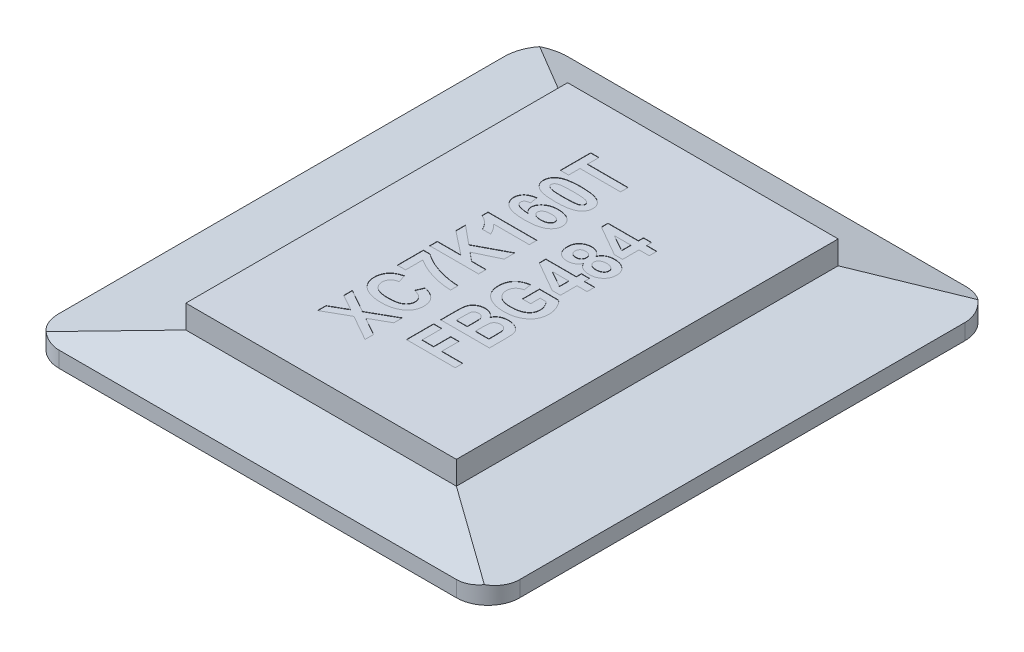
from build123d import *

# Parameters (mm, degrees)
SKETCH1_W           = 14.54
SKETCH1_H           = 16.05
SKETCH2_W           = 8.54
SKETCH2_H           = 12.05
SKETCH3_W           = 8.54
SKETCH3_H           = 12.05
BOSS_EXTRUDE1_DEPTH = 0.735
SKETCH4_W           = 14.54
SKETCH4_H           = 16.05
BOSS_EXTRUDE2_DEPTH = 0.5
FILLET1_R           = 1
CUT_EXTRUDE1_DEPTH  = 0.01


with BuildPart() as part:
    # Sketch1 → Loft1 section 0
    with BuildSketch(Plane(origin=(0, 0, 0), x_dir=(1, 0, 0), z_dir=(0, 1, 0))):
        Rectangle(SKETCH1_W, SKETCH1_H)
    # Sketch2 → Loft1 section 1
    with BuildSketch(Plane(origin=(0, 0.55, 0), x_dir=(1, 0, 0), z_dir=(0, 1, 0))):
        Rectangle(SKETCH2_W, SKETCH2_H)
    loft()

    # Sketch3 → Boss-Extrude1 (add)
    with BuildSketch(Plane(origin=(0, 0.55, 0), x_dir=(1, 0, 0), z_dir=(0, 1, 0))):
        Rectangle(SKETCH3_W, SKETCH3_H)
    extrude(amount=BOSS_EXTRUDE1_DEPTH)

    # Sketch4 → Boss-Extrude2 (add)
    with BuildSketch(Plane.XZ):
        Rectangle(SKETCH4_W, SKETCH4_H)
    extrude(amount=BOSS_EXTRUDE2_DEPTH)

    # Fillet1
    fillet1_edges = [part.edges().sort_by_distance(p)[0] for p in [
        (7.27, -0.25, -8.025),
        (7.27, -0.25, 8.025),
        (-7.27, -0.25, 8.025),
        (-7.27, -0.25, -8.025),
    ]]
    fillet(fillet1_edges, radius=FILLET1_R)

    # Sketch5 → Cut-Extrude1 (cut)
    with BuildSketch(Plane(origin=(0, 1.285, 0), x_dir=(1, 0, 0), z_dir=(0, 1, 0))):
        Polygon((-0.448599451, -4.189884652), (-1.254430285, -3.734904496), (-1.989590662, -4.149858907), (-1.989590662, -3.879372422), (-1.494272059, -3.599504903), (-1.989590662, -3.319950085), (-1.989590662, -3.049150899), (-1.254430285, -3.46410531), (-0.448599451, -3.009125153), (-0.448599451, -3.279924339), (-1.014901213, -3.599504903), (-0.448599451, -3.919398168), align=None)
        with BuildLine():
            Line((-1.008959891, -2.068520128), (-0.908895527, -1.828365654))
            add(Edge.make_bspline(
                [(-0.908895527, -1.828365654), (-0.888708576, -1.833325952), (-0.849373305, -1.842991337), (-0.79314809, -1.861269526), (-0.740994552, -1.881409321), (-0.693218524, -1.904317964), (-0.649545746, -1.929635351), (-0.610060714, -1.957438325), (-0.57469807, -1.987621032), (-0.543577524, -2.020222239), (-0.516763793, -2.05518463), (-0.492987786, -2.091657934), (-0.472973466, -2.130188219), (-0.456549887, -2.170792406), (-0.444239034, -2.213388319), (-0.435006742, -2.257792235), (-0.4297163, -2.304168461), (-0.428967389, -2.335762336), (-0.428586578, -2.35182736)],
                knots=[0, 0, 0, 0, 6.2344e-05, 0.00012148, 0.000177226, 0.000229954, 0.000280261, 0.000328499, 0.000374626, 0.000419526, 0.000463434, 0.000506629, 0.000549986, 0.000593479, 0.000637807, 0.000682821, 0.000729405, 0.000777598, 0.000777598, 0.000777598, 0.000777598], degree=3))
            add(Edge.make_bspline(
                [(-0.428586578, -2.35182736), (-0.429039748, -2.371983967), (-0.429927498, -2.411470283), (-0.439479462, -2.469088407), (-0.453992007, -2.523917016), (-0.474832114, -2.575857277), (-0.501470207, -2.62497078), (-0.534465398, -2.670738686), (-0.572589332, -2.714228946), (-0.602314765, -2.739515537), (-0.617458066, -2.752397518)],
                knots=[0, 0, 0, 0, 6.0417e-05, 0.000118355, 0.000174715, 0.000230286, 0.000285838, 0.000341891, 0.000399255, 0.000458827, 0.000458827, 0.000458827, 0.000458827], degree=3))
            add(Edge.make_bspline(
                [(-0.617458066, -2.752397518), (-0.636154372, -2.766557404), (-0.673819809, -2.795083803), (-0.735930048, -2.830897112), (-0.802657061, -2.86135702), (-0.874061328, -2.886286952), (-0.950221955, -2.90571852), (-1.031175252, -2.919303708), (-1.116882063, -2.927462029), (-1.175611361, -2.928528306), (-1.205648908, -2.929073662)],
                knots=[0, 0, 0, 0, 7.0304e-05, 0.000141634, 0.000214537, 0.000290094, 0.000368212, 0.000450053, 0.000536118, 0.00062622, 0.00062622, 0.00062622, 0.00062622], degree=3))
            add(Edge.make_bspline(
                [(-1.205648908, -2.929073662), (-1.237357784, -2.92857544), (-1.299121356, -2.927604987), (-1.389043244, -2.918867531), (-1.473818183, -2.905547655), (-1.553131079, -2.885688271), (-1.627437351, -2.860810019), (-1.696273637, -2.830073009), (-1.760359858, -2.794384257), (-1.798634311, -2.765266315), (-1.817605036, -2.750834013)],
                knots=[0, 0, 0, 0, 9.5103e-05, 0.000185244, 0.000270787, 0.000352317, 0.000430239, 0.00050555, 0.000578235, 0.000649665, 0.000649665, 0.000649665, 0.000649665], degree=3))
            add(Edge.make_bspline(
                [(-1.817605036, -2.750834013), (-1.832942688, -2.73773161), (-1.863169911, -2.711909586), (-1.902264546, -2.667748555), (-1.935651147, -2.620442631), (-1.962335298, -2.56949366), (-1.984097889, -2.515575248), (-1.998895487, -2.458071926), (-2.007759186, -2.397237144), (-2.008979355, -2.355610354), (-2.009603535, -2.334316096)],
                knots=[0, 0, 0, 0, 6.0455e-05, 0.000119144, 0.000176399, 0.000233752, 0.000291297, 0.000350457, 0.00041144, 0.000475307, 0.000475307, 0.000475307, 0.000475307], degree=3))
            add(Edge.make_bspline(
                [(-2.009603535, -2.334316096), (-2.009186435, -2.316890711), (-2.008366646, -2.282641936), (-2.001812877, -2.232422316), (-1.990288991, -2.184575782), (-1.975173248, -2.138635281), (-1.95494854, -2.095003871), (-1.930407038, -2.05355539), (-1.901629425, -2.014126842), (-1.879257516, -1.990228575), (-1.867949919, -1.978149499)],
                knots=[0, 0, 0, 0, 5.2267e-05, 0.000102728, 0.000151574, 0.000199731, 0.000247582, 0.000295526, 0.00034406, 0.00039366, 0.00039366, 0.00039366, 0.00039366], degree=3))
            add(Edge.make_bspline(
                [(-1.867949919, -1.978149499), (-1.85923495, -1.969751035), (-1.841476295, -1.952637327), (-1.811562948, -1.929593681), (-1.778619194, -1.908259263), (-1.742504444, -1.889016576), (-1.70357168, -1.871127262), (-1.661621333, -1.854860203), (-1.616557969, -1.840549723), (-1.585309464, -1.832489753), (-1.569320332, -1.828365654)],
                knots=[0, 0, 0, 0, 3.6287e-05, 7.3942e-05, 0.00011306, 0.000153914, 0.000196589, 0.000241536, 0.000288806, 0.000338338, 0.000338338, 0.000338338, 0.000338338], degree=3))
            Line((-1.569320332, -1.828365654), (-1.48926884, -2.068520128))
            add(Edge.make_bspline(
                [(-1.48926884, -2.068520128), (-1.499518322, -2.070776847), (-1.51946211, -2.075168047), (-1.548243711, -2.083984459), (-1.574976099, -2.094718088), (-1.600301022, -2.106396418), (-1.623342531, -2.120459071), (-1.645201562, -2.135169048), (-1.664567817, -2.152417875), (-1.682458915, -2.170640782), (-1.697919789, -2.190480544), (-1.711901738, -2.210788323), (-1.723526703, -2.232169573), (-1.732876098, -2.254535107), (-1.740442584, -2.277620024), (-1.745763523, -2.301596343), (-1.748985703, -2.326409191), (-1.749284532, -2.34327036), (-1.749436188, -2.35182736)],
                knots=[0, 0, 0, 0, 3.1477e-05, 6.125e-05, 9.0167e-05, 0.000117862, 0.000144784, 0.000171067, 0.000196777, 0.00022243, 0.000247581, 0.000272125, 0.000296333, 0.000320435, 0.000344762, 0.000369114, 0.000394015, 0.000419673, 0.000419673, 0.000419673, 0.000419673], degree=3))
            add(Edge.make_bspline(
                [(-1.749436188, -2.35182736), (-1.749077156, -2.363937663), (-1.748370546, -2.387771978), (-1.742747865, -2.422690889), (-1.732804846, -2.45573051), (-1.719745076, -2.487380712), (-1.702370307, -2.517137841), (-1.681280242, -2.545167344), (-1.656246006, -2.571203787), (-1.627675101, -2.595805049), (-1.594582467, -2.618347465), (-1.556168928, -2.637198778), (-1.512892631, -2.653002232), (-1.464953466, -2.666504539), (-1.412011158, -2.676629384), (-1.354128901, -2.683649248), (-1.291396289, -2.688032231), (-1.247871109, -2.688616736), (-1.225349079, -2.688919187)],
                knots=[0, 0, 0, 0, 3.6322e-05, 7.1485e-05, 0.00010572, 0.000139636, 0.000173962, 0.000208797, 0.000244628, 0.000282107, 0.000321742, 0.000364395, 0.000410107, 0.000459804, 0.000513648, 0.000571633, 0.000634638, 0.0007022, 0.0007022, 0.0007022, 0.0007022], degree=3))
            add(Edge.make_bspline(
                [(-1.225349079, -2.688919187), (-1.201996416, -2.688577384), (-1.15702626, -2.687919174), (-1.09207428, -2.684082343), (-1.032398287, -2.676789436), (-0.977763632, -2.66745396), (-0.928489658, -2.654679238), (-0.884546187, -2.639072447), (-0.845504213, -2.621095906), (-0.811875975, -2.59965182), (-0.782844794, -2.575891349), (-0.757639403, -2.550629623), (-0.736583806, -2.523378937), (-0.718739309, -2.494868316), (-0.705217222, -2.464315031), (-0.696017098, -2.432080539), (-0.689653818, -2.39835601), (-0.689057906, -2.375206231), (-0.688753926, -2.363397302)],
                knots=[0, 0, 0, 0, 7.0063e-05, 0.000134919, 0.000195077, 0.000250343, 0.000301084, 0.00034757, 0.000390094, 0.000429738, 0.000466855, 0.000502455, 0.000536545, 0.000569957, 0.000603136, 0.000636382, 0.000670365, 0.00070575, 0.00070575, 0.00070575, 0.00070575], degree=3))
            add(Edge.make_bspline(
                [(-0.688753926, -2.363397302), (-0.689033989, -2.354739684), (-0.689589558, -2.337565395), (-0.692808903, -2.31221132), (-0.699504134, -2.287998374), (-0.707289298, -2.264289321), (-0.718526932, -2.241840069), (-0.731636852, -2.220060167), (-0.74741291, -2.199355022), (-0.765672006, -2.179623221), (-0.78624591, -2.160815851), (-0.809720778, -2.143445235), (-0.836074225, -2.127596064), (-0.865261558, -2.112925204), (-0.897107816, -2.099502592), (-0.931832605, -2.087660591), (-0.969269769, -2.076946812), (-0.995475022, -2.071383126), (-1.008959891, -2.068520128)],
                knots=[0, 0, 0, 0, 2.5984e-05, 5.1546e-05, 7.6423e-05, 0.000101244, 0.000126278, 0.000151537, 0.000177429, 0.000204207, 0.000232099, 0.00026093, 0.000291659, 0.000324243, 0.000358857, 0.000395249, 0.00043425, 0.000475595, 0.000475595, 0.000475595, 0.000475595], degree=3))
        make_face()
        with BuildLine():
            Line((-1.709410442, -1.648249798), (-1.969577789, -1.648249798))
            Line((-1.969577789, -1.648249798), (-1.969577789, -0.82772201))
            Line((-1.969577789, -0.82772201), (-1.755064808, -0.82772201))
            add(Edge.make_bspline(
                [(-1.755064808, -0.82772201), (-1.74432112, -0.836295051), (-1.722226747, -0.853925492), (-1.686118217, -0.878668063), (-1.647607176, -0.904605755), (-1.605130994, -0.929604842), (-1.559995334, -0.955443107), (-1.511130033, -0.98057242), (-1.459534019, -1.006660276), (-1.385702719, -1.040823329), (-1.289722509, -1.081753529), (-1.170030469, -1.124524693), (-1.046288623, -1.16136953), (-0.920194542, -1.19223885), (-0.795030874, -1.216617478), (-0.674342785, -1.234606803), (-0.559513125, -1.24591625), (-0.484896457, -1.247312931), (-0.448599451, -1.247992341)],
                knots=[0, 0, 0, 0, 4.1221e-05, 8.4771e-05, 0.000131257, 0.000180487, 0.000232577, 0.000287265, 0.0003453, 0.000406016, 0.00053129, 0.000658192, 0.000787103, 0.000918461, 0.001047492, 0.001169503, 0.001284445, 0.001393319, 0.001393319, 0.001393319, 0.001393319], degree=3))
            Line((-0.448599451, -1.247992341), (-0.448599451, -1.488146815))
            add(Edge.make_bspline(
                [(-0.448599451, -1.488146815), (-0.476233249, -1.48722236), (-0.531667491, -1.485367876), (-0.614673088, -1.478558243), (-0.697691237, -1.469223782), (-0.780596231, -1.456972735), (-0.863546639, -1.442043417), (-0.946328402, -1.423847913), (-1.029094262, -1.40275718), (-1.111580867, -1.37930013), (-1.192868815, -1.352533009), (-1.27281271, -1.324315888), (-1.350481381, -1.293208596), (-1.426436114, -1.260463733), (-1.500156953, -1.22514509), (-1.57175852, -1.187430641), (-1.641812748, -1.148269483), (-1.686910094, -1.119878427), (-1.709410442, -1.105713323)],
                knots=[0, 0, 0, 0, 8.2937e-05, 0.000166374, 0.00024977, 0.000333528, 0.000417742, 0.00050257, 0.00058774, 0.000673946, 0.00075978, 0.000844444, 0.000928235, 0.001010725, 0.001092546, 0.00117339, 0.001253484, 0.001333235, 0.001333235, 0.001333235, 0.001333235], degree=3))
            Line((-1.709410442, -1.105713323), (-1.709410442, -1.648249798))
        make_face()
        Polygon((-0.448599451, -0.607580409), (-1.989590662, -0.607580409), (-1.989590662, -0.367425934), (-1.247863561, -0.367425934), (-1.989590662, 0.218263298), (-1.989590662, 0.523146908), (-1.402337924, 0.039085546), (-0.448599451, 0.543159781), (-0.448599451, 0.203566345), (-1.175942299, -0.147284333), (-0.908895527, -0.367425934), (-0.448599451, -0.367425934), align=None)
        with BuildLine():
            Line((-0.448599451, 1.233603895), (-0.448599451, 0.993449421))
            Line((-0.448599451, 0.993449421), (-1.569320332, 0.993449421))
            add(Edge.make_bspline(
                [(-1.569320332, 0.993449421), (-1.557100473, 0.981800339), (-1.532865632, 0.958697482), (-1.498992817, 0.921971737), (-1.467881616, 0.883813696), (-1.438722561, 0.844593114), (-1.412723456, 0.803662697), (-1.388733213, 0.761599291), (-1.36740026, 0.718156857), (-1.355256959, 0.688225399), (-1.34917873, 0.673243455)],
                knots=[0, 0, 0, 0, 5.0639e-05, 0.000100429, 0.000149757, 0.00019829, 0.000246952, 0.000295124, 0.000343512, 0.000392005, 0.000392005, 0.000392005, 0.000392005], degree=3))
            Line((-1.34917873, 0.673243455), (-1.609346078, 0.673243455))
            add(Edge.make_bspline(
                [(-1.609346078, 0.673243455), (-1.617026576, 0.690510563), (-1.633016938, 0.726459705), (-1.665055647, 0.779175628), (-1.705624768, 0.832088602), (-1.744139402, 0.876291586), (-1.778472979, 0.910657676), (-1.805485682, 0.935176574), (-1.834013187, 0.956989211), (-1.862816815, 0.977517591), (-1.893171195, 0.995351845), (-1.924287395, 1.01121427), (-1.956371055, 1.025268714), (-1.978478316, 1.032602903), (-1.989590662, 1.036289477)],
                knots=[0, 0, 0, 0, 5.6654e-05, 0.000117951, 0.000184494, 0.000256505, 0.000293652, 0.00033019, 0.000365844, 0.000401324, 0.000436236, 0.000471338, 0.000506074, 0.000541182, 0.000541182, 0.000541182, 0.000541182], degree=3))
            Line((-1.989590662, 1.036289477), (-1.989590662, 1.233603895))
            Line((-1.989590662, 1.233603895), (-0.448599451, 1.233603895))
        make_face()
        with BuildLine():
            Line((-1.609346078, 2.394350522), (-1.569320332, 2.154196047))
            add(Edge.make_bspline(
                [(-1.569320332, 2.154196047), (-1.583436701, 2.152615765), (-1.610022369, 2.149639584), (-1.646925118, 2.140982331), (-1.678217211, 2.129187436), (-1.704341424, 2.11460974), (-1.724660179, 2.096122458), (-1.739097341, 2.074310096), (-1.748048925, 2.049267843), (-1.748961491, 2.031485917), (-1.749436188, 2.022236167)],
                knots=[0, 0, 0, 0, 4.2588e-05, 8.0207e-05, 0.000113367, 0.000142651, 0.000169428, 0.000194926, 0.000220442, 0.000248103, 0.000248103, 0.000248103, 0.000248103], degree=3))
            add(Edge.make_bspline(
                [(-1.749436188, 2.022236167), (-1.749236878, 2.016059668), (-1.748843808, 2.003878621), (-1.744454612, 1.986112466), (-1.737924536, 1.968973271), (-1.728386934, 1.952732858), (-1.716405496, 1.937173822), (-1.701420333, 1.922872741), (-1.684170887, 1.90898464), (-1.663713834, 1.895937162), (-1.639096903, 1.883770934), (-1.609164138, 1.873529516), (-1.574099921, 1.863830038), (-1.533554626, 1.85550647), (-1.48750281, 1.848508045), (-1.435995638, 1.842261975), (-1.379050426, 1.83729756), (-1.339284146, 1.835124164), (-1.318534019, 1.833990081)],
                knots=[0, 0, 0, 0, 1.8492e-05, 3.6469e-05, 5.4586e-05, 7.3359e-05, 9.2749e-05, 0.000113314, 0.000135339, 0.000159106, 0.000185956, 0.000217508, 0.000253847, 0.00029506, 0.000341586, 0.00039356, 0.000450691, 0.000513031, 0.000513031, 0.000513031, 0.000513031], degree=3))
            add(Edge.make_bspline(
                [(-1.318534019, 1.833990081), (-1.328906797, 1.841397048), (-1.349014902, 1.855755792), (-1.375728042, 1.880004154), (-1.398453515, 1.905414903), (-1.417203951, 1.932063705), (-1.431365089, 1.960378335), (-1.441934568, 1.989923121), (-1.447843855, 2.0211698), (-1.448772992, 2.042434542), (-1.449243095, 2.053193579)],
                knots=[0, 0, 0, 0, 3.8212e-05, 7.4076e-05, 0.000107965, 0.00014032, 0.000171506, 0.000202658, 0.000234181, 0.000266463, 0.000266463, 0.000266463, 0.000266463], degree=3))
            add(Edge.make_bspline(
                [(-1.449243095, 2.053193579), (-1.448788675, 2.065098859), (-1.447885513, 2.088760644), (-1.441672944, 2.123657994), (-1.430392758, 2.157147527), (-1.415228278, 2.18951373), (-1.396234947, 2.221084129), (-1.37195091, 2.25073063), (-1.344081432, 2.279681308), (-1.311935655, 2.307014265), (-1.276319407, 2.332154229), (-1.237455588, 2.354229665), (-1.195872921, 2.372882647), (-1.151475022, 2.388443303), (-1.104153883, 2.3997018), (-1.054122204, 2.408138948), (-1.001370424, 2.41367524), (-0.965195921, 2.41413085), (-0.946732365, 2.414363394)],
                knots=[0, 0, 0, 0, 3.5715e-05, 7.0984e-05, 0.00010589, 0.000141424, 0.000178053, 0.000216096, 0.000256123, 0.000298486, 0.000342471, 0.000386726, 0.000432351, 0.000479028, 0.000527643, 0.000578074, 0.000631188, 0.000686558, 0.000686558, 0.000686558, 0.000686558], degree=3))
            add(Edge.make_bspline(
                [(-0.946732365, 2.414363394), (-0.927019409, 2.414001981), (-0.888665723, 2.413298811), (-0.832871474, 2.407894299), (-0.780256407, 2.399259172), (-0.730956994, 2.386876506), (-0.684862763, 2.37073944), (-0.641850923, 2.351546189), (-0.602273666, 2.328279244), (-0.566381541, 2.301677185), (-0.534163695, 2.272627473), (-0.505897131, 2.241685291), (-0.481932761, 2.209003486), (-0.462302513, 2.174640512), (-0.44714578, 2.13840763), (-0.43667844, 2.100349085), (-0.42977415, 2.0607392), (-0.428985935, 2.033731155), (-0.428586578, 2.020047259)],
                knots=[0, 0, 0, 0, 5.913e-05, 0.000115044, 0.000167994, 0.00021896, 0.000267319, 0.000314342, 0.000360035, 0.000404753, 0.000448147, 0.000489985, 0.000530264, 0.000569476, 0.000608444, 0.000647746, 0.00068769, 0.000728712, 0.000728712, 0.000728712, 0.000728712], degree=3))
            add(Edge.make_bspline(
                [(-0.428586578, 2.020047259), (-0.429103068, 2.004993997), (-0.430122931, 1.9752698), (-0.438961314, 1.931885125), (-0.452621996, 1.890294117), (-0.472752924, 1.851068797), (-0.497929149, 1.81340523), (-0.529168022, 1.778133282), (-0.5658492, 1.744836501), (-0.607978058, 1.71329978), (-0.656719125, 1.684585945), (-0.713074864, 1.660483205), (-0.77632393, 1.639506576), (-0.847142658, 1.623017106), (-0.925005712, 1.609518147), (-1.010348375, 1.600487478), (-1.102900479, 1.594802408), (-1.167073322, 1.594165635), (-1.200332988, 1.593835607)],
                knots=[0, 0, 0, 0, 4.5117e-05, 8.9088e-05, 0.000132301, 0.000176072, 0.000220911, 0.000267889, 0.000317025, 0.000369309, 0.000425514, 0.000486284, 0.000552834, 0.000625189, 0.000704204, 0.000789775, 0.000882505, 0.000982275, 0.000982275, 0.000982275, 0.000982275], degree=3))
            add(Edge.make_bspline(
                [(-1.200332988, 1.593835607), (-1.234113854, 1.594147417), (-1.29933463, 1.594749429), (-1.39347525, 1.600689529), (-1.480227777, 1.610537583), (-1.559605442, 1.624212651), (-1.631897776, 1.641350426), (-1.696762384, 1.663213158), (-1.754426366, 1.68867249), (-1.804783843, 1.718226247), (-1.847935996, 1.751457701), (-1.88596162, 1.78620736), (-1.91828421, 1.823437413), (-1.943856172, 1.863634616), (-1.96468543, 1.905407631), (-1.978994524, 1.94978101), (-1.988129718, 1.996322593), (-1.989098785, 2.028238269), (-1.989590662, 2.044437948)],
                knots=[0, 0, 0, 0, 0.000101333, 0.000195643, 0.000282837, 0.000363138, 0.00043716, 0.000505491, 0.000568197, 0.000625955, 0.000680179, 0.000731295, 0.000780305, 0.000827577, 0.000873867, 0.000919948, 0.000967049, 0.001015599, 0.001015599, 0.001015599, 0.001015599], degree=3))
            add(Edge.make_bspline(
                [(-1.989590662, 2.044437948), (-1.989277097, 2.055605673), (-1.988659245, 2.077610664), (-1.984175404, 2.109857313), (-1.97704076, 2.140799616), (-1.966688451, 2.170393286), (-1.953024994, 2.198491303), (-1.937200688, 2.225656749), (-1.917840172, 2.251115045), (-1.895594152, 2.275136421), (-1.870590794, 2.297833902), (-1.842215621, 2.318167461), (-1.810788439, 2.336371126), (-1.776218856, 2.352112552), (-1.738944484, 2.366435256), (-1.698340709, 2.377688202), (-1.654960817, 2.387560205), (-1.624809462, 2.392048606), (-1.609346078, 2.394350522)],
                knots=[0, 0, 0, 0, 3.3496e-05, 6.6e-05, 9.7477e-05, 0.00012863, 0.00015982, 0.000191086, 0.000222794, 0.000255545, 0.000289201, 0.000323916, 0.000360065, 0.00039798, 0.000437763, 0.000479728, 0.000524261, 0.000571145, 0.000571145, 0.000571145, 0.000571145], degree=3))
        make_face()
        with BuildLine():
            add(Edge.make_bspline(
                [(-0.9564261, 1.854002954), (-0.945165966, 1.854230226), (-0.923250358, 1.854672565), (-0.891286304, 1.856736794), (-0.861366075, 1.860646942), (-0.833657864, 1.866794348), (-0.807895382, 1.873868538), (-0.784032152, 1.882501045), (-0.762355321, 1.893150472), (-0.742983805, 1.90550716), (-0.725502463, 1.918436234), (-0.710447063, 1.932201436), (-0.697732935, 1.946510766), (-0.687165628, 1.961010864), (-0.678613777, 1.976003834), (-0.673168418, 1.991722691), (-0.669516506, 2.007790936), (-0.668999505, 2.018672561), (-0.668741053, 2.024112374)],
                knots=[0, 0, 0, 0, 3.3785e-05, 6.5755e-05, 9.6049e-05, 0.0001242, 0.000150831, 0.000176158, 0.000200212, 0.000223116, 0.000245005, 0.000265367, 0.000284194, 0.000302333, 0.000319129, 0.000335746, 0.000352061, 0.000368369, 0.000368369, 0.000368369, 0.000368369], degree=3))
            add(Edge.make_bspline(
                [(-0.668741053, 2.024112374), (-0.669404082, 2.034547105), (-0.670714078, 2.055163785), (-0.683149336, 2.084399245), (-0.703416802, 2.110135683), (-0.725586927, 2.128934641), (-0.747215946, 2.141966058), (-0.766299617, 2.150690638), (-0.787968113, 2.157776916), (-0.811841904, 2.164051224), (-0.838301136, 2.168722555), (-0.867158183, 2.171567564), (-0.89843199, 2.174007092), (-0.92014715, 2.17413999), (-0.931410009, 2.17420892)],
                knots=[0, 0, 0, 0, 3.1184e-05, 6.1613e-05, 9.351e-05, 0.000128784, 0.000148144, 0.000169132, 0.000191579, 0.000216456, 0.000243138, 0.000272076, 0.000303423, 0.0003372, 0.0003372, 0.0003372, 0.0003372], degree=3))
            add(Edge.make_bspline(
                [(-0.931410009, 2.17420892), (-0.943087355, 2.174118786), (-0.965630752, 2.173944781), (-0.998208288, 2.171777957), (-1.02825234, 2.167986444), (-1.055980789, 2.163127216), (-1.081249306, 2.156538463), (-1.104246117, 2.148846405), (-1.124767765, 2.139516014), (-1.147790253, 2.125190674), (-1.172126199, 2.105415129), (-1.193288239, 2.077268358), (-1.206955178, 2.046220646), (-1.208373413, 2.024248335), (-1.20908862, 2.013167834)],
                knots=[0, 0, 0, 0, 3.5028e-05, 6.7623e-05, 9.7876e-05, 0.000125844, 0.000152011, 0.000176139, 0.000198525, 0.000219441, 0.000257397, 0.000291794, 0.000324315, 0.000357399, 0.000357399, 0.000357399, 0.000357399], degree=3))
            add(Edge.make_bspline(
                [(-1.20908862, 2.013167834), (-1.208297801, 2.002423717), (-1.20672006, 1.980988457), (-1.194083969, 1.950451352), (-1.173571183, 1.922991691), (-1.150772262, 1.903038837), (-1.128991014, 1.888851518), (-1.110085978, 1.879465361), (-1.089193157, 1.871692535), (-1.066423332, 1.865106079), (-1.04160205, 1.860261793), (-1.015000176, 1.856453135), (-0.986378111, 1.854264715), (-0.966644721, 1.854092258), (-0.9564261, 1.854002954)],
                knots=[0, 0, 0, 0, 3.2154e-05, 6.4149e-05, 9.7485e-05, 0.000134256, 0.000154378, 0.000175355, 0.000197424, 0.000221177, 0.000246382, 0.000273225, 0.000301765, 0.000332416, 0.000332416, 0.000332416, 0.000332416], degree=3))
        make_face(mode=Mode.SUBTRACT)
        with BuildLine():
            add(Edge.make_bspline(
                [(-1.989590662, 2.984104869), (-1.989041429, 2.999047655), (-1.987957672, 3.028533009), (-1.979625778, 3.071552954), (-1.966089476, 3.112507799), (-1.946886607, 3.151114592), (-1.92215355, 3.187396919), (-1.892041164, 3.221445936), (-1.856562354, 3.253288326), (-1.815398696, 3.283128873), (-1.767255731, 3.309944576), (-1.711267089, 3.332846995), (-1.647239458, 3.352081252), (-1.5751806, 3.367754376), (-1.494988137, 3.380187393), (-1.406654719, 3.388607192), (-1.310261619, 3.393967851), (-1.243285015, 3.394643098), (-1.208463218, 3.394994165)],
                knots=[0, 0, 0, 0, 4.4805e-05, 8.8409e-05, 0.00013093, 0.000173862, 0.000217314, 0.000262292, 0.000309894, 0.000360059, 0.000414516, 0.000474795, 0.000541168, 0.000614836, 0.000695859, 0.000784475, 0.000880933, 0.000985392, 0.000985392, 0.000985392, 0.000985392], degree=3))
            add(Edge.make_bspline(
                [(-1.208463218, 3.394994165), (-1.173745799, 3.394642329), (-1.106977798, 3.393965684), (-1.010894803, 3.388616988), (-0.922778341, 3.380149901), (-0.842772168, 3.367817886), (-0.770765488, 3.351956655), (-0.706751473, 3.33299356), (-0.650858289, 3.309851599), (-0.602757487, 3.283157788), (-0.561730271, 3.253261877), (-0.526038287, 3.221766218), (-0.496024972, 3.18770011), (-0.471384847, 3.151487084), (-0.452001829, 3.113069044), (-0.438660715, 3.072361268), (-0.430158699, 3.029589556), (-0.429117789, 3.000302045), (-0.428586578, 2.985355674)],
                knots=[0, 0, 0, 0, 0.000104146, 0.000200293, 0.000288597, 0.00036962, 0.000442983, 0.000509655, 0.000569645, 0.000624103, 0.000674268, 0.00072166, 0.000766638, 0.00081009, 0.000852743, 0.000895263, 0.000938254, 0.000983058, 0.000983058, 0.000983058, 0.000983058], degree=3))
            add(Edge.make_bspline(
                [(-0.428586578, 2.985355674), (-0.42917351, 2.970420628), (-0.430330905, 2.940969622), (-0.438113495, 2.897856915), (-0.451881429, 2.857048545), (-0.47057549, 2.818248935), (-0.495437195, 2.782174343), (-0.525162627, 2.748009389), (-0.560340351, 2.71615001), (-0.593768477, 2.691902801), (-0.623332929, 2.67367663), (-0.648059726, 2.660961209), (-0.674840235, 2.649110304), (-0.703522444, 2.637702622), (-0.734668235, 2.627929771), (-0.76768458, 2.618492478), (-0.802746315, 2.610081877), (-0.839904867, 2.602649612), (-0.879061002, 2.595629472), (-0.920525858, 2.590270001), (-0.963851477, 2.585027552), (-1.009458106, 2.581538705), (-1.056980359, 2.578275939), (-1.106720171, 2.576265078), (-1.158418156, 2.574459605), (-1.193660235, 2.574464094), (-1.211590229, 2.574466377)],
                knots=[0, 0, 0, 0, 4.4805e-05, 8.8352e-05, 0.000130873, 0.000173667, 0.000217119, 0.000261891, 0.000309261, 0.000359173, 0.000385558, 0.000413391, 0.000442505, 0.000473398, 0.000505932, 0.000540381, 0.000576407, 0.000614061, 0.000654057, 0.000695716, 0.000739468, 0.000784965, 0.00083291, 0.000882365, 0.000934297, 0.000988083, 0.000988083, 0.000988083, 0.000988083], degree=3))
            add(Edge.make_bspline(
                [(-1.211590229, 2.574466377), (-1.246203608, 2.574817194), (-1.312763658, 2.575491798), (-1.408532081, 2.580852155), (-1.496241462, 2.58926777), (-1.575911374, 2.60172462), (-1.64763958, 2.617438075), (-1.711510167, 2.636532071), (-1.767320777, 2.659602742), (-1.815419324, 2.686304211), (-1.856447074, 2.716198312), (-1.892138928, 2.747694412), (-1.922152275, 2.78176041), (-1.946792391, 2.817973464), (-1.966175412, 2.856391497), (-1.979516526, 2.897099275), (-1.988018541, 2.939870986), (-1.989059451, 2.969158498), (-1.989590662, 2.984104869)],
                knots=[0, 0, 0, 0, 0.000103834, 0.000199668, 0.000287661, 0.000368066, 0.000441429, 0.000507802, 0.000567792, 0.00062225, 0.000672415, 0.000719807, 0.000764785, 0.000808237, 0.00085089, 0.00089341, 0.000936401, 0.000981205, 0.000981205, 0.000981205, 0.000981205], degree=3))
        make_face()
        with BuildLine():
            add(Edge.make_bspline(
                [(-1.749436188, 2.984730271), (-1.749116705, 2.979176696), (-1.748479832, 2.968105918), (-1.743913186, 2.952005039), (-1.736643582, 2.936689173), (-1.72607788, 2.922426474), (-1.712344904, 2.909464634), (-1.696310501, 2.896694408), (-1.676985026, 2.885272082), (-1.654170282, 2.874162248), (-1.625397895, 2.864696938), (-1.589512849, 2.856494908), (-1.545588124, 2.849906869), (-1.493722015, 2.844460625), (-1.433881834, 2.839710616), (-1.365879559, 2.836838139), (-1.289880881, 2.834934801), (-1.236503504, 2.834737415), (-1.208463218, 2.834633725)],
                knots=[0, 0, 0, 0, 1.6647e-05, 3.3184e-05, 4.9828e-05, 6.7278e-05, 8.6074e-05, 0.000106342, 0.000128651, 0.000153267, 0.00018234, 0.000219279, 0.000263594, 0.000315496, 0.000375717, 0.000443645, 0.000519655, 0.000603774, 0.000603774, 0.000603774, 0.000603774], degree=3))
            add(Edge.make_bspline(
                [(-1.208463218, 2.834633725), (-1.180422903, 2.834736118), (-1.127149674, 2.834930654), (-1.051255497, 2.836844723), (-0.983357303, 2.839709208), (-0.923517093, 2.844463764), (-0.871753513, 2.849887032), (-0.828030009, 2.856473896), (-0.792381268, 2.864761637), (-0.763762339, 2.874080649), (-0.741108173, 2.885332248), (-0.721861139, 2.896811991), (-0.705536993, 2.909250441), (-0.69211291, 2.922547473), (-0.681519314, 2.936674076), (-0.674267775, 2.952008955), (-0.669696473, 2.968104934), (-0.669060223, 2.979176368), (-0.668741053, 2.984730271)],
                knots=[0, 0, 0, 0, 8.4119e-05, 0.000159816, 0.000227744, 0.000287966, 0.000339867, 0.000383874, 0.000420508, 0.000449581, 0.000473915, 0.000496225, 0.000516739, 0.000535313, 0.000552763, 0.000569406, 0.000585944, 0.000602591, 0.000602591, 0.000602591, 0.000602591], degree=3))
            add(Edge.make_bspline(
                [(-0.668741053, 2.984730271), (-0.669053548, 2.990388289), (-0.669670794, 3.001564069), (-0.674250731, 3.017777966), (-0.681623262, 3.033122903), (-0.691989443, 3.047633454), (-0.705882302, 3.06069635), (-0.72206433, 3.07333295), (-0.741594262, 3.084454009), (-0.764309372, 3.095618661), (-0.792959536, 3.105113452), (-0.82874169, 3.112768926), (-0.872330668, 3.120048965), (-0.924035544, 3.125326327), (-0.983787288, 3.129655187), (-1.051566444, 3.132647648), (-1.127358685, 3.134517912), (-1.180527324, 3.134720417), (-1.208463218, 3.134826818)],
                knots=[0, 0, 0, 0, 1.6958e-05, 3.3496e-05, 5.014e-05, 6.7842e-05, 8.6638e-05, 0.000107153, 0.000129302, 0.000153918, 0.000182991, 0.000219554, 0.000263611, 0.000315513, 0.000375399, 0.000443327, 0.000519024, 0.00060283, 0.00060283, 0.00060283, 0.00060283], degree=3))
            add(Edge.make_bspline(
                [(-1.208463218, 3.134826818), (-1.236503294, 3.13471953), (-1.289880273, 3.134515298), (-1.365881626, 3.132657899), (-1.433867459, 3.129638074), (-1.493726533, 3.12534761), (-1.545634489, 3.120023828), (-1.589430622, 3.112755155), (-1.625434919, 3.10515666), (-1.654185059, 3.095622582), (-1.676880446, 3.084434717), (-1.696403383, 3.073437673), (-1.712317649, 3.060591537), (-1.726196905, 3.047645178), (-1.736551758, 3.033120045), (-1.743927081, 3.017778702), (-1.7485063, 3.00156388), (-1.749123642, 2.990388225), (-1.749436188, 2.984730271)],
                knots=[0, 0, 0, 0, 8.4119e-05, 0.000160128, 0.000228057, 0.000288255, 0.000340156, 0.000384521, 0.00042139, 0.000450462, 0.000475079, 0.000497228, 0.000517495, 0.000536291, 0.000553994, 0.000570638, 0.000587176, 0.000604134, 0.000604134, 0.000604134, 0.000604134], degree=3))
        make_face(mode=Mode.SUBTRACT)
        Polygon((-0.448599451, 3.875303114), (-1.729423315, 3.875303114), (-1.729423315, 3.515071402), (-1.989590662, 3.515071402), (-1.989590662, 4.4756893), (-1.729423315, 4.4756893), (-1.729423315, 4.115457588), (-0.448599451, 4.115457588), align=None)
        Polygon((1.747606751, -3.540660185), (0.20661554, -3.540660185), (0.20661554, -2.680106652), (0.466782887, -2.680106652), (0.466782887, -3.300505711), (0.827014599, -3.300505711), (0.827014599, -2.760158143), (1.087181946, -2.760158143), (1.087181946, -3.300505711), (1.747606751, -3.300505711), align=None)
        with BuildLine():
            Line((0.20661554, -2.45996505), (0.20661554, -1.942131965))
            add(Edge.make_bspline(
                [(0.20661554, -1.942131965), (0.206768028, -1.925141548), (0.207061846, -1.892404102), (0.208383233, -1.845250657), (0.21161725, -1.80208783), (0.215686633, -1.762884609), (0.220330813, -1.727514458), (0.227095038, -1.696164207), (0.234276048, -1.66855019), (0.246062637, -1.637070349), (0.264991422, -1.601541147), (0.29508477, -1.563348992), (0.331772519, -1.528335972), (0.375024144, -1.497418533), (0.423384456, -1.471570588), (0.475661575, -1.452623136), (0.531245953, -1.441427334), (0.569297503, -1.440024949), (0.588736331, -1.439308534)],
                knots=[0, 0, 0, 0, 5.0974e-05, 9.8218e-05, 0.000141484, 0.000180782, 0.00021647, 0.000248422, 0.000276945, 0.000301979, 0.000349123, 0.000397036, 0.00044724, 0.000500785, 0.000556042, 0.000611237, 0.000667043, 0.000725326, 0.000725326, 0.000725326, 0.000725326], degree=3))
            add(Edge.make_bspline(
                [(0.588736331, -1.439308534), (0.606593621, -1.439946353), (0.641692631, -1.441200003), (0.693036707, -1.449988857), (0.741659188, -1.465168711), (0.78697356, -1.486010386), (0.828261291, -1.5114435), (0.864133799, -1.541074547), (0.894927828, -1.573894106), (0.910371973, -1.598917579), (0.91801063, -1.61129416)],
                knots=[0, 0, 0, 0, 5.3563e-05, 0.00010528, 0.000155721, 0.000205953, 0.000254546, 0.000300749, 0.000345238, 0.000388775, 0.000388775, 0.000388775, 0.000388775], degree=3))
            add(Edge.make_bspline(
                [(0.91801063, -1.61129416), (0.92540275, -1.595363184), (0.940118834, -1.563648113), (0.971656277, -1.521329652), (1.010677976, -1.484947672), (1.056236817, -1.453860808), (1.108265096, -1.42925654), (1.166011416, -1.411832251), (1.228846408, -1.401007076), (1.272567987, -1.399869681), (1.295128203, -1.399282788)],
                knots=[0, 0, 0, 0, 5.2582e-05, 0.00010468, 0.000157106, 0.000212008, 0.000269495, 0.00032904, 0.000392477, 0.000460108, 0.000460108, 0.000460108, 0.000460108], degree=3))
            add(Edge.make_bspline(
                [(1.295128203, -1.399282788), (1.309102371, -1.399522627), (1.33647756, -1.399992467), (1.376743261, -1.403693172), (1.415218654, -1.410468475), (1.452257577, -1.418897886), (1.487339512, -1.430774162), (1.521073042, -1.444361887), (1.553012687, -1.461067555), (1.583079603, -1.480095646), (1.611090282, -1.500452688), (1.636218387, -1.52228066), (1.65889335, -1.544589929), (1.678340676, -1.568334154), (1.695360888, -1.592700086), (1.709567519, -1.618084943), (1.720597686, -1.644594998), (1.725886312, -1.662834003), (1.728531981, -1.671958181)],
                knots=[0, 0, 0, 0, 4.1921e-05, 8.2122e-05, 0.000121141, 0.000159064, 0.000195948, 0.000232126, 0.00026807, 0.000303901, 0.000338801, 0.000371836, 0.000403676, 0.000434105, 0.00046377, 0.000492746, 0.000521201, 0.000549686, 0.000549686, 0.000549686, 0.000549686], degree=3))
            add(Edge.make_bspline(
                [(1.728531981, -1.671958181), (1.730062598, -1.679449984), (1.733532118, -1.696432002), (1.737504616, -1.725235737), (1.74029882, -1.760325163), (1.743340552, -1.80168953), (1.744866365, -1.849568272), (1.746562263, -1.903763774), (1.747439127, -1.964331087), (1.747548989, -2.006756712), (1.747606751, -2.029062881)],
                knots=[0, 0, 0, 0, 2.2936e-05, 5.199e-05, 8.7152e-05, 0.000128525, 0.000176405, 0.000230837, 0.000291196, 0.000358115, 0.000358115, 0.000358115, 0.000358115], degree=3))
            Line((1.747606751, -2.029062881), (1.747606751, -2.45996505))
            Line((1.747606751, -2.45996505), (0.20661554, -2.45996505))
        make_face()
        with BuildLine():
            Line((0.466782887, -2.219810576), (0.807001726, -2.219810576))
            Line((0.807001726, -2.219810576), (0.807001726, -2.035942306))
            add(Edge.make_bspline(
                [(0.807001726, -2.035942306), (0.807037019, -2.02280865), (0.807104245, -1.997791705), (0.806653937, -1.962249693), (0.80651573, -1.930661977), (0.805742219, -1.903149454), (0.805302396, -1.879580564), (0.804227096, -1.859995399), (0.803510704, -1.844226222), (0.802455239, -1.835080628), (0.801998508, -1.83112306)],
                knots=[0, 0, 0, 0, 3.94e-05, 7.505e-05, 0.000106634, 0.000134159, 0.00015762, 0.000177342, 0.000193005, 0.000204954, 0.000204954, 0.000204954, 0.000204954], degree=3))
            add(Edge.make_bspline(
                [(0.801998508, -1.83112306), (0.799929171, -1.819786363), (0.795962527, -1.798055414), (0.784926977, -1.767703635), (0.7694952, -1.741374214), (0.749868961, -1.719138647), (0.726313491, -1.701301532), (0.698841021, -1.688203387), (0.667299087, -1.680755487), (0.645062341, -1.679906344), (0.633452594, -1.679463008)],
                knots=[0, 0, 0, 0, 3.4529e-05, 6.6188e-05, 9.6327e-05, 0.000125568, 0.000154587, 0.000184379, 0.000216233, 0.000251033, 0.000251033, 0.000251033, 0.000251033], degree=3))
            add(Edge.make_bspline(
                [(0.633452594, -1.679463008), (0.622999964, -1.679893889), (0.603058088, -1.680715937), (0.574556739, -1.686648355), (0.549167191, -1.696987412), (0.527286272, -1.711568609), (0.508722207, -1.728652349), (0.494233824, -1.748118779), (0.482926022, -1.768944168), (0.476879983, -1.78869832), (0.474342733, -1.807847409), (0.471996702, -1.827525178), (0.47080822, -1.852699709), (0.468963918, -1.883322677), (0.468397154, -1.919515781), (0.467166195, -1.961095204), (0.467143686, -2.008112994), (0.466907608, -2.041258626), (0.466782887, -2.058769489)],
                knots=[0, 0, 0, 0, 3.1347e-05, 5.9804e-05, 8.6865e-05, 0.000113057, 0.00013828, 0.00016217, 0.000185531, 0.000209073, 0.000223623, 0.000243444, 0.000268509, 0.000299194, 0.000335479, 0.000377079, 0.000423985, 0.00047652, 0.00047652, 0.00047652, 0.00047652], degree=3))
            Line((0.466782887, -2.058769489), (0.466782887, -2.219810576))
        make_face(mode=Mode.SUBTRACT)
        with BuildLine():
            Line((1.067169073, -2.219810576), (1.487439403, -2.219810576))
            Line((1.487439403, -2.219810576), (1.487439403, -1.965897251))
            add(Edge.make_bspline(
                [(1.487439403, -1.965897251), (1.487352941, -1.952555339), (1.487188113, -1.92712089), (1.486678063, -1.890942562), (1.485421318, -1.858518432), (1.483665493, -1.829829738), (1.481071136, -1.80482455), (1.478527348, -1.783585385), (1.474998663, -1.766180707), (1.470274505, -1.747797096), (1.461081948, -1.728095217), (1.446599188, -1.70695578), (1.427896554, -1.687853311), (1.405585329, -1.670824425), (1.379456129, -1.656502899), (1.34965852, -1.646782401), (1.316783905, -1.640193968), (1.293704605, -1.639696438), (1.281682054, -1.639437263)],
                knots=[0, 0, 0, 0, 4.0027e-05, 7.6306e-05, 0.000108538, 0.000137368, 0.000162509, 0.000183958, 0.000201497, 0.000215758, 0.00024081, 0.000266223, 0.000292318, 0.00032065, 0.000350173, 0.000381224, 0.000414341, 0.00045035, 0.00045035, 0.00045035, 0.00045035], degree=3))
            add(Edge.make_bspline(
                [(1.281682054, -1.639437263), (1.269357355, -1.639855318), (1.245683269, -1.640658346), (1.21166178, -1.646841376), (1.181163826, -1.657797811), (1.154146568, -1.672883474), (1.131360597, -1.691889906), (1.111779509, -1.713396011), (1.096357249, -1.738068978), (1.08684028, -1.761230069), (1.080977335, -1.782582929), (1.077567944, -1.802509192), (1.073893106, -1.826026646), (1.07176973, -1.853311887), (1.06931534, -1.884245486), (1.068402185, -1.918990459), (1.067285449, -1.957447234), (1.067209046, -1.984345373), (1.067169073, -1.99841817)],
                knots=[0, 0, 0, 0, 3.6964e-05, 7.1002e-05, 0.000103248, 0.000133773, 0.000163321, 0.000191887, 0.000220691, 0.000250133, 0.000266671, 0.000287032, 0.000310736, 0.000338056, 0.00036909, 0.000403823, 0.000442296, 0.000484512, 0.000484512, 0.000484512, 0.000484512], degree=3))
            Line((1.067169073, -1.99841817), (1.067169073, -2.219810576))
        make_face(mode=Mode.SUBTRACT)
        with BuildLine():
            Line((1.18724631, -0.598767873), (0.927078963, -0.598767873))
            Line((0.927078963, -0.598767873), (0.927078963, -0.058420306))
            Line((0.927078963, -0.058420306), (1.532468367, -0.058420306))
            add(Edge.make_bspline(
                [(1.532468367, -0.058420306), (1.540479003, -0.06562217), (1.556659637, -0.080169172), (1.579659817, -0.104100141), (1.601420017, -0.130535712), (1.622709203, -0.158783055), (1.64274019, -0.189575885), (1.662436066, -0.222063614), (1.680885036, -0.257147769), (1.704386829, -0.306023234), (1.729480429, -0.368898006), (1.751683411, -0.44548028), (1.764970612, -0.522421804), (1.766739037, -0.57380636), (1.767619624, -0.599393276)],
                knots=[0, 0, 0, 0, 3.231e-05, 6.5262e-05, 9.9454e-05, 0.000134977, 0.000171316, 0.000209607, 0.000248915, 0.000290175, 0.000372282, 0.000451659, 0.000529028, 0.000605764, 0.000605764, 0.000605764, 0.000605764], degree=3))
            add(Edge.make_bspline(
                [(1.767619624, -0.599393276), (1.767268012, -0.61472282), (1.766573144, -0.645017617), (1.762591945, -0.689871262), (1.755340691, -0.733318209), (1.745393358, -0.775352189), (1.732380507, -0.815946408), (1.716961726, -0.85540628), (1.697961083, -0.893156601), (1.676809168, -0.929763666), (1.652173358, -0.964301633), (1.625487598, -0.997749327), (1.595192299, -1.028550044), (1.562490945, -1.057922115), (1.526806423, -1.085340949), (1.488342648, -1.111087696), (1.44676639, -1.134421572), (1.402816466, -1.156343246), (1.356394715, -1.176023604), (1.307755089, -1.192803527), (1.257286173, -1.207350877), (1.20460423, -1.218779054), (1.15001459, -1.227807129), (1.09345552, -1.234329967), (1.03492201, -1.238577652), (0.995151162, -1.238976789), (0.974922237, -1.239179805)],
                knots=[0, 0, 0, 0, 4.5994e-05, 9.0894e-05, 0.000134951, 0.000178031, 0.000220358, 0.000262747, 0.00030498, 0.000347027, 0.000389449, 0.000432133, 0.000475255, 0.000518882, 0.000563915, 0.000610141, 0.000657615, 0.00070684, 0.000757426, 0.000808752, 0.000861112, 0.000914905, 0.000970374, 0.001027042, 0.001085658, 0.001146335, 0.001146335, 0.001146335, 0.001146335], degree=3))
            add(Edge.make_bspline(
                [(0.974922237, -1.239179805), (0.95427678, -1.238975102), (0.91367375, -1.238572516), (0.85399076, -1.234352231), (0.796501712, -1.227794436), (0.741227589, -1.218920815), (0.688327728, -1.206958877), (0.637645423, -1.192587792), (0.589290028, -1.175443243), (0.543276713, -1.155707075), (0.499972169, -1.133919684), (0.459423159, -1.110310117), (0.421551061, -1.085361901), (0.386418763, -1.058874591), (0.354423946, -1.030454407), (0.32487281, -1.000939225), (0.298599903, -0.969341899), (0.274627985, -0.936650067), (0.25399411, -0.901862345), (0.235701282, -0.865724491), (0.220847333, -0.827602758), (0.20816366, -0.788079009), (0.198524314, -0.746759946), (0.191818593, -0.703793979), (0.187117448, -0.659327176), (0.186775976, -0.629112506), (0.186602667, -0.613777528)],
                knots=[0, 0, 0, 0, 6.1927e-05, 0.000121792, 0.000179391, 0.000235477, 0.000289643, 0.000342003, 0.000393432, 0.000443443, 0.000492109, 0.00053877, 0.000584129, 0.000628095, 0.000670632, 0.000712423, 0.000753261, 0.000793793, 0.000833907, 0.000874461, 0.000915167, 0.000956505, 0.000998904, 0.001042293, 0.001086912, 0.001132896, 0.001132896, 0.001132896, 0.001132896], degree=3))
            add(Edge.make_bspline(
                [(0.186602667, -0.613777528), (0.18694751, -0.595418046), (0.18761932, -0.559650844), (0.193300079, -0.507337385), (0.202950645, -0.457858699), (0.216397044, -0.411205905), (0.233313491, -0.367235992), (0.254276925, -0.326082151), (0.279485019, -0.287908722), (0.308051199, -0.252295297), (0.340377698, -0.219636972), (0.376519248, -0.19020869), (0.416265901, -0.16383789), (0.459324331, -0.140372767), (0.50625242, -0.120399965), (0.556407126, -0.102808679), (0.610439161, -0.088833322), (0.647789514, -0.081954765), (0.666911616, -0.078433179)],
                knots=[0, 0, 0, 0, 5.5067e-05, 0.00010728, 0.000157629, 0.000206123, 0.000252753, 0.000298764, 0.000344384, 0.000389752, 0.000435523, 0.000481969, 0.000529322, 0.000578436, 0.000628857, 0.000682161, 0.000737756, 0.000796077, 0.000796077, 0.000796077, 0.000796077], degree=3))
            Line((0.666911616, -0.078433179), (0.706937362, -0.318587653))
            add(Edge.make_bspline(
                [(0.706937362, -0.318587653), (0.696686019, -0.32116549), (0.676618896, -0.326211637), (0.647702381, -0.335875342), (0.620857212, -0.347553385), (0.59562852, -0.360404899), (0.572154886, -0.374624324), (0.550760578, -0.390845392), (0.53096545, -0.408182799), (0.513458297, -0.427427554), (0.497872905, -0.447781892), (0.483926939, -0.468930787), (0.472736404, -0.491409089), (0.463308514, -0.51461176), (0.455721128, -0.538739856), (0.450418477, -0.563970755), (0.447237747, -0.590137758), (0.446926811, -0.607931561), (0.446770014, -0.616904539)],
                knots=[0, 0, 0, 0, 3.1705e-05, 6.2063e-05, 9.1338e-05, 0.000119448, 0.000146961, 0.00017354, 0.000199898, 0.000225792, 0.000251435, 0.000276762, 0.000301655, 0.000326624, 0.000351845, 0.000377419, 0.000403872, 0.00043078, 0.00043078, 0.00043078, 0.00043078], degree=3))
            add(Edge.make_bspline(
                [(0.446770014, -0.616904539), (0.447097295, -0.630788319), (0.447740249, -0.658063465), (0.453779206, -0.697936508), (0.463908684, -0.735726435), (0.477551712, -0.771636917), (0.495689323, -0.805265968), (0.517256063, -0.837124791), (0.543278739, -0.866622338), (0.572914128, -0.89426088), (0.606926771, -0.919008667), (0.645034913, -0.940753797), (0.687397575, -0.958712213), (0.733802882, -0.973418652), (0.784336868, -0.984875964), (0.838981628, -0.993205612), (0.897797251, -0.998279907), (0.9383256, -0.99877122), (0.95928718, -0.999025331)],
                knots=[0, 0, 0, 0, 4.1632e-05, 8.1787e-05, 0.000120622, 0.000158833, 0.000196743, 0.000234993, 0.000273999, 0.000314492, 0.000356335, 0.000399891, 0.000445837, 0.000494096, 0.000545754, 0.000601124, 0.000659813, 0.000722685, 0.000722685, 0.000722685, 0.000722685], degree=3))
            add(Edge.make_bspline(
                [(0.95928718, -0.999025331), (0.981812324, -0.998660715), (1.025468965, -0.997954041), (1.088883078, -0.992644128), (1.148165503, -0.983726581), (1.203346715, -0.970887463), (1.254473852, -0.954783569), (1.301409995, -0.934993204), (1.344400029, -0.911834093), (1.369866615, -0.892714476), (1.382371821, -0.883325909)],
                knots=[0, 0, 0, 0, 6.7569e-05, 0.000130958, 0.000190751, 0.00024726, 0.000300761, 0.000351347, 0.000399912, 0.000446768, 0.000446768, 0.000446768, 0.000446768], degree=3))
            add(Edge.make_bspline(
                [(1.382371821, -0.883325909), (1.392397449, -0.87491308), (1.412103583, -0.858377024), (1.437357401, -0.829818092), (1.459418701, -0.799695984), (1.476838667, -0.766841472), (1.490810357, -0.731975046), (1.500320223, -0.694752562), (1.506532887, -0.655471783), (1.507141342, -0.628499229), (1.507452276, -0.614715631)],
                knots=[0, 0, 0, 0, 3.9213e-05, 7.7075e-05, 0.000114044, 0.00015098, 0.000188317, 0.000226468, 0.000266005, 0.000307324, 0.000307324, 0.000307324, 0.000307324], degree=3))
            add(Edge.make_bspline(
                [(1.507452276, -0.614715631), (1.507023144, -0.601450345), (1.506149721, -0.57445124), (1.499115518, -0.533759847), (1.488600953, -0.492112252), (1.473085522, -0.450456881), (1.45472556, -0.409210516), (1.432668904, -0.36984461), (1.407348408, -0.332857587), (1.388190745, -0.309996421), (1.378619407, -0.29857478)],
                knots=[0, 0, 0, 0, 3.9773e-05, 8.0951e-05, 0.000123575, 0.000168485, 0.00021411, 0.000258909, 0.000303665, 0.000348351, 0.000348351, 0.000348351, 0.000348351], degree=3))
            Line((1.378619407, -0.29857478), (1.18724631, -0.29857478))
            Line((1.18724631, -0.29857478), (1.18724631, -0.598767873))
        make_face()
        Polygon((1.747606751, 0.622017372), (1.427400785, 0.622017372), (1.427400785, 0.101682677), (1.168171541, 0.101682677), (0.20661554, 0.653287486), (0.20661554, 0.862171846), (1.167233438, 0.862171846), (1.167233438, 1.022274829), (1.427400785, 1.022274829), (1.427400785, 0.862171846), (1.747606751, 0.862171846), align=None)
        Polygon((1.167233438, 0.622017372), (0.649713053, 0.622017372), (1.167233438, 0.330267209), align=None, mode=Mode.SUBTRACT)
        with BuildLine():
            add(Edge.make_bspline(
                [(0.918948733, 1.334975968), (0.911062464, 1.319688357), (0.895726918, 1.289960253), (0.865635167, 1.250890234), (0.832068239, 1.217127282), (0.793790619, 1.189852277), (0.75165688, 1.168100273), (0.705226067, 1.153382819), (0.654882807, 1.144020362), (0.619946427, 1.14292093), (0.601869779, 1.142352066)],
                knots=[0, 0, 0, 0, 5.1511e-05, 0.000100168, 0.000147266, 0.000193868, 0.000240578, 0.000288933, 0.000339473, 0.00039366, 0.00039366, 0.00039366, 0.00039366], degree=3))
            add(Edge.make_bspline(
                [(0.601869779, 1.142352066), (0.587157919, 1.142612373), (0.558477639, 1.143119833), (0.516610154, 1.148232585), (0.477062684, 1.156664425), (0.439703937, 1.168287061), (0.404363373, 1.182789404), (0.371767359, 1.201565845), (0.341275447, 1.223105078), (0.313415939, 1.247887456), (0.288343152, 1.27544135), (0.266413472, 1.305518156), (0.247738579, 1.337979815), (0.232931338, 1.372829016), (0.220797486, 1.409701105), (0.212528104, 1.448913908), (0.207373988, 1.490458178), (0.206872715, 1.518932586), (0.20661554, 1.533541191)],
                knots=[0, 0, 0, 0, 4.4119e-05, 8.6008e-05, 0.000126302, 0.000165271, 0.000203252, 0.000240642, 0.000277865, 0.000315078, 0.000352267, 0.000389419, 0.000426537, 0.000464354, 0.000502821, 0.00054281, 0.000584389, 0.000628195, 0.000628195, 0.000628195, 0.000628195], degree=3))
            add(Edge.make_bspline(
                [(0.20661554, 1.533541191), (0.206965102, 1.548986801), (0.207642802, 1.578931356), (0.213184978, 1.62242894), (0.221491703, 1.663255486), (0.234769993, 1.700971459), (0.250375823, 1.736297434), (0.270415684, 1.768370047), (0.293629165, 1.797834535), (0.320704664, 1.823838302), (0.349867977, 1.847265339), (0.381150303, 1.867287731), (0.41377621, 1.884705374), (0.448052988, 1.898693278), (0.483907115, 1.90937565), (0.52112627, 1.917190316), (0.560051098, 1.921990793), (0.586533694, 1.922563187), (0.599993572, 1.922854108)],
                knots=[0, 0, 0, 0, 4.6318e-05, 8.9797e-05, 0.00013138, 0.000171034, 0.000209517, 0.000247006, 0.00028417, 0.000321761, 0.000359365, 0.000396228, 0.000433017, 0.000470181, 0.000507081, 0.000545104, 0.000584162, 0.000624531, 0.000624531, 0.000624531, 0.000624531], degree=3))
            add(Edge.make_bspline(
                [(0.599993572, 1.922854108), (0.618081459, 1.922355235), (0.653303255, 1.9213838), (0.704071759, 1.910884626), (0.751408364, 1.894881347), (0.794256492, 1.871278742), (0.833201266, 1.842929549), (0.867365836, 1.809369882), (0.896597152, 1.770951831), (0.911436383, 1.742255895), (0.918948733, 1.727728598)],
                knots=[0, 0, 0, 0, 5.4188e-05, 0.000105517, 0.000154866, 0.000203556, 0.000251652, 0.000298972, 0.000346753, 0.000395743, 0.000395743, 0.000395743, 0.000395743], degree=3))
            add(Edge.make_bspline(
                [(0.918948733, 1.727728598), (0.927892768, 1.74495504), (0.945377452, 1.778630994), (0.980275998, 1.822488265), (1.019145838, 1.860658283), (1.064432882, 1.890770046), (1.114730959, 1.914589104), (1.1705871, 1.930797312), (1.23158641, 1.941052746), (1.274028845, 1.942246925), (1.296066307, 1.942866981)],
                knots=[0, 0, 0, 0, 5.8103e-05, 0.000113585, 0.000167327, 0.000220926, 0.000275899, 0.000333675, 0.00039485, 0.00046092, 0.00046092, 0.00046092, 0.00046092], degree=3))
            add(Edge.make_bspline(
                [(1.296066307, 1.942866981), (1.318936972, 1.942364567), (1.363556034, 1.941384392), (1.42829902, 1.930899894), (1.489159223, 1.915055666), (1.545181486, 1.891649985), (1.596115797, 1.863156916), (1.641260088, 1.829414294), (1.679822201, 1.790351748), (1.711367907, 1.746262554), (1.736618097, 1.69865185), (1.754430405, 1.64762349), (1.765883484, 1.593880775), (1.767035709, 1.55694812), (1.767619624, 1.538231708)],
                knots=[0, 0, 0, 0, 6.8553e-05, 0.000133742, 0.000196245, 0.000256813, 0.000315342, 0.00037094, 0.000425336, 0.000479318, 0.000533029, 0.000586436, 0.000641017, 0.000697096, 0.000697096, 0.000697096, 0.000697096], degree=3))
            add(Edge.make_bspline(
                [(1.767619624, 1.538231708), (1.767304453, 1.523512037), (1.766684825, 1.494573037), (1.760451461, 1.452185613), (1.750965559, 1.411664648), (1.73705853, 1.373182873), (1.719102422, 1.336767929), (1.6973816, 1.30221835), (1.671999823, 1.269463549), (1.642571852, 1.239369015), (1.610219314, 1.211731246), (1.574545501, 1.187915031), (1.536339693, 1.167526001), (1.495369574, 1.150872238), (1.45167805, 1.138033798), (1.405271221, 1.129200482), (1.356254935, 1.123315979), (1.322663841, 1.122670184), (1.305447341, 1.122339193)],
                knots=[0, 0, 0, 0, 4.4131e-05, 8.6761e-05, 0.000128248, 0.000168803, 0.000209219, 0.000249823, 0.000291044, 0.000333282, 0.000375883, 0.000418466, 0.000461693, 0.000505593, 0.000550909, 0.000598069, 0.000647174, 0.000698804, 0.000698804, 0.000698804, 0.000698804], degree=3))
            add(Edge.make_bspline(
                [(1.305447341, 1.122339193), (1.283306537, 1.122950035), (1.240435714, 1.124132795), (1.178545184, 1.134658681), (1.121405708, 1.151797771), (1.069134104, 1.175805642), (1.02257455, 1.206814018), (0.981306234, 1.243367524), (0.94609565, 1.286249371), (0.92806274, 1.318617038), (0.918948733, 1.334975968)],
                knots=[0, 0, 0, 0, 6.6382e-05, 0.000128534, 0.000187688, 0.000244909, 0.000300415, 0.000354897, 0.000409791, 0.000465886, 0.000465886, 0.000465886, 0.000465886], degree=3))
        make_face()
        with BuildLine():
            add(Edge.make_bspline(
                [(0.625322364, 1.382506541), (0.639131606, 1.382979583), (0.665371774, 1.383878452), (0.702273408, 1.392404305), (0.734336459, 1.406369177), (0.760661736, 1.426529828), (0.781426474, 1.45070298), (0.796534587, 1.478251552), (0.805575278, 1.508903421), (0.806518004, 1.530352825), (0.807001726, 1.541358719)],
                knots=[0, 0, 0, 0, 4.1372e-05, 7.8615e-05, 0.000112906, 0.00014549, 0.000177202, 0.000207849, 0.000239119, 0.000272073, 0.000272073, 0.000272073, 0.000272073], degree=3))
            add(Edge.make_bspline(
                [(0.807001726, 1.541358719), (0.806513728, 1.552570081), (0.805562528, 1.574423111), (0.796607833, 1.605621269), (0.781433363, 1.633561626), (0.760683733, 1.658054111), (0.73436121, 1.678507165), (0.702349022, 1.692887591), (0.665362063, 1.701316493), (0.639128258, 1.702231154), (0.625322364, 1.702712507)],
                knots=[0, 0, 0, 0, 3.3577e-05, 6.5448e-05, 9.6369e-05, 0.00012832, 0.000161094, 0.000195514, 0.000232757, 0.000274129, 0.000274129, 0.000274129, 0.000274129], degree=3))
            add(Edge.make_bspline(
                [(0.625322364, 1.702712507), (0.611932223, 1.702229425), (0.586418276, 1.701308947), (0.55050089, 1.692862299), (0.519244605, 1.67858587), (0.493122537, 1.658702295), (0.472356251, 1.634656256), (0.457698253, 1.607152017), (0.448076022, 1.577017064), (0.447212501, 1.555714384), (0.446770014, 1.544798432)],
                knots=[0, 0, 0, 0, 4.0125e-05, 7.6454e-05, 0.000109892, 0.000142476, 0.000174188, 0.00020441, 0.00023547, 0.000268113, 0.000268113, 0.000268113, 0.000268113], degree=3))
            add(Edge.make_bspline(
                [(0.446770014, 1.544798432), (0.447397126, 1.533489165), (0.448619095, 1.511452305), (0.457393637, 1.479837183), (0.472931106, 1.451791246), (0.493702028, 1.427173163), (0.51983383, 1.406794578), (0.551337284, 1.392908037), (0.586871971, 1.383792564), (0.612126934, 1.382947879), (0.625322364, 1.382506541)],
                knots=[0, 0, 0, 0, 3.3916e-05, 6.6088e-05, 9.7433e-05, 0.000129384, 0.000162158, 0.000195879, 0.000231979, 0.00027148, 0.00027148, 0.00027148, 0.00027148], degree=3))
        make_face(mode=Mode.SUBTRACT)
        with BuildLine():
            add(Edge.make_bspline(
                [(1.276678836, 1.362493668), (1.28637529, 1.36272409), (1.305271081, 1.363173122), (1.332876317, 1.365201876), (1.358792218, 1.369269933), (1.382890573, 1.374955431), (1.405394392, 1.38170082), (1.42600931, 1.390475688), (1.44495379, 1.400876248), (1.467362879, 1.416301423), (1.490627874, 1.438435354), (1.512271011, 1.467889101), (1.525142118, 1.500764045), (1.526689461, 1.523637936), (1.527465149, 1.535104696)],
                knots=[0, 0, 0, 0, 2.9096e-05, 5.6701e-05, 8.2972e-05, 0.000107699, 0.000130942, 0.000153361, 0.000174773, 0.000195677, 0.00023483, 0.00027049, 0.000304638, 0.000338964, 0.000338964, 0.000338964, 0.000338964], degree=3))
            add(Edge.make_bspline(
                [(1.527465149, 1.535104696), (1.52682921, 1.54657989), (1.525572885, 1.569249628), (1.512851946, 1.601352693), (1.492687262, 1.630205515), (1.470266956, 1.651324181), (1.448553698, 1.665921456), (1.430145423, 1.676072622), (1.409453101, 1.684077939), (1.387100389, 1.690922414), (1.3627396, 1.69629447), (1.336378805, 1.699834766), (1.30810892, 1.702553576), (1.288568669, 1.702658657), (1.278555043, 1.702712507)],
                knots=[0, 0, 0, 0, 3.429e-05, 6.7742e-05, 0.000101917, 0.000139301, 0.000159336, 0.000180324, 0.000202216, 0.000225758, 0.000250416, 0.000276949, 0.000305515, 0.00033554, 0.00033554, 0.00033554, 0.00033554], degree=3))
            add(Edge.make_bspline(
                [(1.278555043, 1.702712507), (1.261626934, 1.702143502), (1.229378671, 1.701059541), (1.183558244, 1.692069038), (1.143301163, 1.676513868), (1.109308641, 1.654764943), (1.08178102, 1.628961201), (1.061768688, 1.599423243), (1.049043433, 1.566735015), (1.047790578, 1.54366107), (1.0471562, 1.531977685)],
                knots=[0, 0, 0, 0, 5.0754e-05, 9.6687e-05, 0.000139367, 0.000179443, 0.000217042, 0.000251734, 0.000285771, 0.000320683, 0.000320683, 0.000320683, 0.000320683], degree=3))
            add(Edge.make_bspline(
                [(1.0471562, 1.531977685), (1.047965954, 1.520520105), (1.049569169, 1.497835464), (1.061697199, 1.465222596), (1.082173535, 1.436050335), (1.109627058, 1.410012977), (1.143679792, 1.388563169), (1.183591621, 1.373185339), (1.22853893, 1.364168653), (1.260166856, 1.363068188), (1.276678836, 1.362493668)],
                knots=[0, 0, 0, 0, 3.4326e-05, 6.7961e-05, 0.000102829, 0.000140428, 0.000180768, 0.000222751, 0.000268072, 0.000317577, 0.000317577, 0.000317577, 0.000317577], degree=3))
        make_face(mode=Mode.SUBTRACT)
        Polygon((1.747606751, 2.583278913), (1.427400785, 2.583278913), (1.427400785, 2.062944218), (1.168171541, 2.062944218), (0.20661554, 2.614549027), (0.20661554, 2.823433387), (1.167233438, 2.823433387), (1.167233438, 2.98353637), (1.427400785, 2.98353637), (1.427400785, 2.823433387), (1.747606751, 2.823433387), align=None)
        Polygon((1.167233438, 2.583278913), (0.649713053, 2.583278913), (1.167233438, 2.291528751), align=None, mode=Mode.SUBTRACT)
    extrude(amount=-CUT_EXTRUDE1_DEPTH, mode=Mode.SUBTRACT)


solid = part.part
